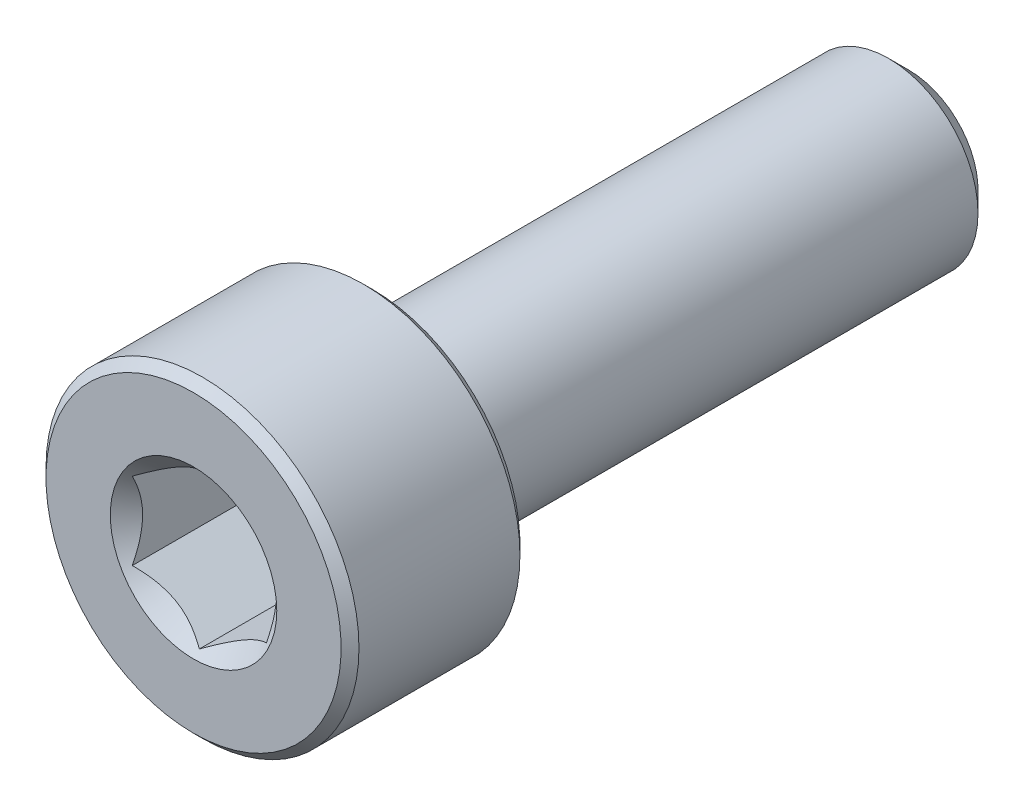
from build123d import *

# Parameters (mm, degrees)
CUT_EXTRUDE1_DEPTH = 3
SKETCH4_R          = 1.861954618
CUT_EXTRUDE2_DEPTH = 3
CUT_EXTRUDE2_DRAFT = -45


with BuildPart() as part:
    # Sketch2 → Revolve1 (revolve)
    with BuildSketch(Plane(origin=(0, 0, 0), x_dir=(0, 0, -1), z_dir=(1, 0, 0))):
        with BuildLine():
            Line((-8, 0), (-8, 3.3))
            Line((-8, 3.3), (-7.8, 3.5))
            Line((-7.8, 3.5), (-4.2, 3.5))
            Line((-4.2, 3.5), (-4, 3.3))
            Line((-4, 3.3), (-4, 2.2))
            ThreePointArc((-4, 2.2), (-3.941421356, 2.058578644), (-3.8, 2))
            Line((-3.8, 2), (7.545336663, 2))
            Line((7.545336663, 2), (8, 1.545336663))
            Line((8, 1.545336663), (8, 0))
            Line((8, 0), (-8, 0))
        make_face()
    revolve(axis=Axis((0, 0, -8), (0, 0, 1)))

    # Sketch3 → Cut-Extrude1 (cut)
    with BuildSketch(Plane.XY.offset(8)):
        Polygon((1.5, -0.866025404), (1.5, 0.866025404), (0, 1.732050808), (-1.5, 0.866025404), (-1.5, -0.866025404), (0, -1.732050808), align=None)
    extrude(amount=-CUT_EXTRUDE1_DEPTH, mode=Mode.SUBTRACT)


with BuildPart() as cut_extrude2_tool:
    # Sketch4 → Cut-Extrude2 (with draft: the straight prism first)
    with BuildSketch(Plane.XY.offset(8)):
        Circle(SKETCH4_R)
    extrude(amount=-CUT_EXTRUDE2_DEPTH)
    # Cut-Extrude2: the draft: its side faces are tilted about the plane it starts from
    cut_extrude2_sides = [cut_extrude2_tool.faces().sort_by_distance(p)[0] for p in [
        (-1.861954618, 0, 6.5),
    ]]
    draft(cut_extrude2_sides, Plane.XY.offset(8), CUT_EXTRUDE2_DRAFT)


with BuildPart() as part_1:
    add(part.part)

    # Cut-Extrude2: cut by cut_extrude2_tool
    add(cut_extrude2_tool.part, mode=Mode.SUBTRACT)


solid = part_1.part
